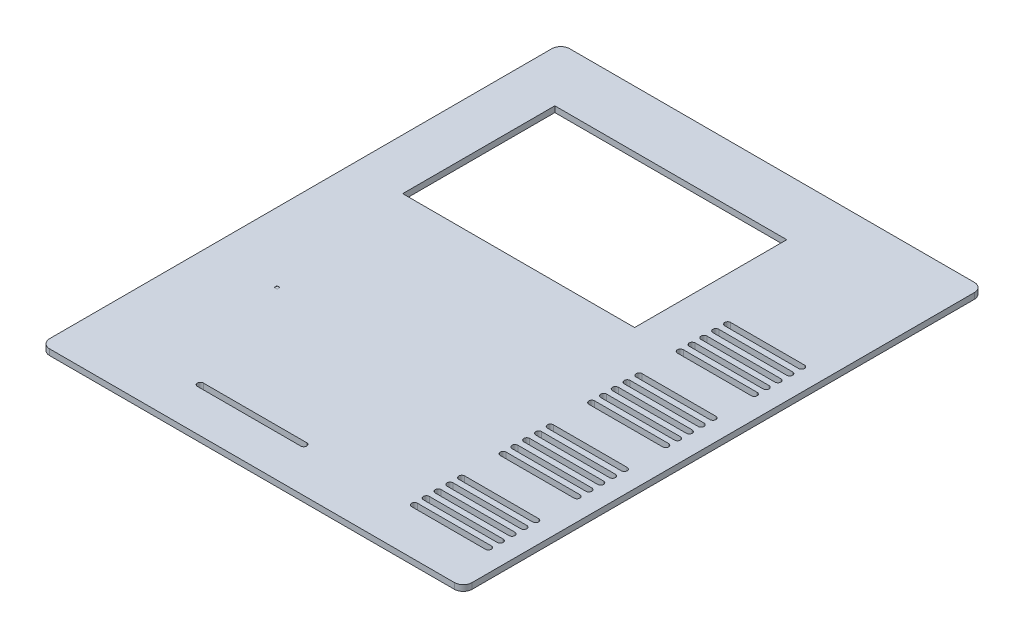
from build123d import *

# Parameters (mm, degrees)
SKETCH1_W           = 143
SKETCH1_H           = 176
SKETCH1_W_2         = 78.5
SKETCH1_H_2         = 51.5
BOSS_EXTRUDE1_DEPTH = 2
SKETCH2_W           = 1
SKETCH2_H           = 1
CUT_EXTRUDE1_DEPTH  = 0.1
FILLET1_R           = 3


with BuildPart() as part:
    # Sketch1 → Boss-Extrude1 (new body)
    with BuildSketch(Plane(origin=(0, 0, 0), x_dir=(1, 0, 0), z_dir=(0, 1, 0))):
        with Locations((-31.5, -3)):
            Rectangle(SKETCH1_W, SKETCH1_H)
        with Locations((-46.5, 40)):
            Rectangle(SKETCH1_W_2, SKETCH1_H_2, mode=Mode.SUBTRACT)
        with BuildLine():
            Line((-64, -77), (-29, -77))
            ThreePointArc((-29, -77), (-28, -76), (-29, -75))
            Line((-29, -75), (-64, -75))
            ThreePointArc((-64, -75), (-65, -76), (-64, -77))
        make_face(mode=Mode.SUBTRACT)
        with BuildLine():
            Line((7.5, -70), (32.5, -70))
            ThreePointArc((32.5, -70), (33.5, -71), (32.5, -72))
            Line((32.5, -72), (7.5, -72))
            ThreePointArc((7.5, -72), (6.5, -71), (7.5, -70))
        make_face(mode=Mode.SUBTRACT)
        with BuildLine():
            Line((7.5, -76), (32.5, -76))
            ThreePointArc((32.5, -76), (33.5, -75), (32.5, -74))
            Line((32.5, -74), (7.5, -74))
            ThreePointArc((7.5, -74), (6.5, -75), (7.5, -76))
        make_face(mode=Mode.SUBTRACT)
        with BuildLine():
            Line((7.5, -66), (32.5, -66))
            ThreePointArc((32.5, -66), (33.5, -67), (32.5, -68))
            Line((32.5, -68), (7.5, -68))
            ThreePointArc((7.5, -68), (6.5, -67), (7.5, -66))
        make_face(mode=Mode.SUBTRACT)
        with BuildLine():
            Line((7.5, -62), (32.5, -62))
            ThreePointArc((32.5, -62), (33.5, -63), (32.5, -64))
            Line((32.5, -64), (7.5, -64))
            ThreePointArc((7.5, -64), (6.5, -63), (7.5, -62))
        make_face(mode=Mode.SUBTRACT)
        with BuildLine():
            Line((7.5, -58), (32.5, -58))
            ThreePointArc((32.5, -58), (33.5, -59), (32.5, -60))
            Line((32.5, -60), (7.5, -60))
            ThreePointArc((7.5, -60), (6.5, -59), (7.5, -58))
        make_face(mode=Mode.SUBTRACT)
        with BuildLine():
            Line((7.5, -40), (32.5, -40))
            ThreePointArc((32.5, -40), (33.5, -41), (32.5, -42))
            Line((32.5, -42), (7.5, -42))
            ThreePointArc((7.5, -42), (6.5, -41), (7.5, -40))
        make_face(mode=Mode.SUBTRACT)
        with BuildLine():
            Line((7.5, -46), (32.5, -46))
            ThreePointArc((32.5, -46), (33.5, -45), (32.5, -44))
            Line((32.5, -44), (7.5, -44))
            ThreePointArc((7.5, -44), (6.5, -45), (7.5, -46))
        make_face(mode=Mode.SUBTRACT)
        with BuildLine():
            Line((7.5, -36), (32.5, -36))
            ThreePointArc((32.5, -36), (33.5, -37), (32.5, -38))
            Line((32.5, -38), (7.5, -38))
            ThreePointArc((7.5, -38), (6.5, -37), (7.5, -36))
        make_face(mode=Mode.SUBTRACT)
        with BuildLine():
            Line((7.5, -32), (32.5, -32))
            ThreePointArc((32.5, -32), (33.5, -33), (32.5, -34))
            Line((32.5, -34), (7.5, -34))
            ThreePointArc((7.5, -34), (6.5, -33), (7.5, -32))
        make_face(mode=Mode.SUBTRACT)
        with BuildLine():
            Line((7.5, -28), (32.5, -28))
            ThreePointArc((32.5, -28), (33.5, -29), (32.5, -30))
            Line((32.5, -30), (7.5, -30))
            ThreePointArc((7.5, -30), (6.5, -29), (7.5, -28))
        make_face(mode=Mode.SUBTRACT)
        with BuildLine():
            Line((7.5, -10), (32.5, -10))
            ThreePointArc((32.5, -10), (33.5, -11), (32.5, -12))
            Line((32.5, -12), (7.5, -12))
            ThreePointArc((7.5, -12), (6.5, -11), (7.5, -10))
        make_face(mode=Mode.SUBTRACT)
        with BuildLine():
            Line((7.5, -16), (32.5, -16))
            ThreePointArc((32.5, -16), (33.5, -15), (32.5, -14))
            Line((32.5, -14), (7.5, -14))
            ThreePointArc((7.5, -14), (6.5, -15), (7.5, -16))
        make_face(mode=Mode.SUBTRACT)
        with BuildLine():
            Line((7.5, -6), (32.5, -6))
            ThreePointArc((32.5, -6), (33.5, -7), (32.5, -8))
            Line((32.5, -8), (7.5, -8))
            ThreePointArc((7.5, -8), (6.5, -7), (7.5, -6))
        make_face(mode=Mode.SUBTRACT)
        with BuildLine():
            Line((7.5, -2), (32.5, -2))
            ThreePointArc((32.5, -2), (33.5, -3), (32.5, -4))
            Line((32.5, -4), (7.5, -4))
            ThreePointArc((7.5, -4), (6.5, -3), (7.5, -2))
        make_face(mode=Mode.SUBTRACT)
        with BuildLine():
            Line((7.5, 2), (32.5, 2))
            ThreePointArc((32.5, 2), (33.5, 1), (32.5, 0))
            Line((32.5, 0), (7.5, 0))
            ThreePointArc((7.5, 0), (6.5, 1), (7.5, 2))
        make_face(mode=Mode.SUBTRACT)
        with BuildLine():
            Line((7.5, 20), (32.5, 20))
            ThreePointArc((32.5, 20), (33.5, 19), (32.5, 18))
            Line((32.5, 18), (7.5, 18))
            ThreePointArc((7.5, 18), (6.5, 19), (7.5, 20))
        make_face(mode=Mode.SUBTRACT)
        with BuildLine():
            Line((7.5, 14), (32.5, 14))
            ThreePointArc((32.5, 14), (33.5, 15), (32.5, 16))
            Line((32.5, 16), (7.5, 16))
            ThreePointArc((7.5, 16), (6.5, 15), (7.5, 14))
        make_face(mode=Mode.SUBTRACT)
        with BuildLine():
            Line((7.5, 24), (32.5, 24))
            ThreePointArc((32.5, 24), (33.5, 23), (32.5, 22))
            Line((32.5, 22), (7.5, 22))
            ThreePointArc((7.5, 22), (6.5, 23), (7.5, 24))
        make_face(mode=Mode.SUBTRACT)
        with BuildLine():
            Line((7.5, 28), (32.5, 28))
            ThreePointArc((32.5, 28), (33.5, 27), (32.5, 26))
            Line((32.5, 26), (7.5, 26))
            ThreePointArc((7.5, 26), (6.5, 27), (7.5, 28))
        make_face(mode=Mode.SUBTRACT)
        with BuildLine():
            Line((7.5, 32), (32.5, 32))
            ThreePointArc((32.5, 32), (33.5, 31), (32.5, 30))
            Line((32.5, 30), (7.5, 30))
            ThreePointArc((7.5, 30), (6.5, 31), (7.5, 32))
        make_face(mode=Mode.SUBTRACT)
    extrude(amount=BOSS_EXTRUDE1_DEPTH)

    # Sketch2 → Cut-Extrude1 (cut)
    with BuildSketch(Plane(origin=(0, 2, 0), x_dir=(1, 0, 0), z_dir=(0, 1, 0))):
        with Locations((-79.5, -34.5)):
            Rectangle(SKETCH2_W, SKETCH2_H)
    extrude(amount=-CUT_EXTRUDE1_DEPTH, mode=Mode.SUBTRACT)

    # Fillet1
    fillet1_edges = [part.edges().sort_by_distance(p)[0] for p in [
        (-103, 1, -85),
        (40, 1, -85),
        (40, 1, 91),
        (-103, 1, 91),
    ]]
    fillet(fillet1_edges, radius=FILLET1_R)


solid = part.part
